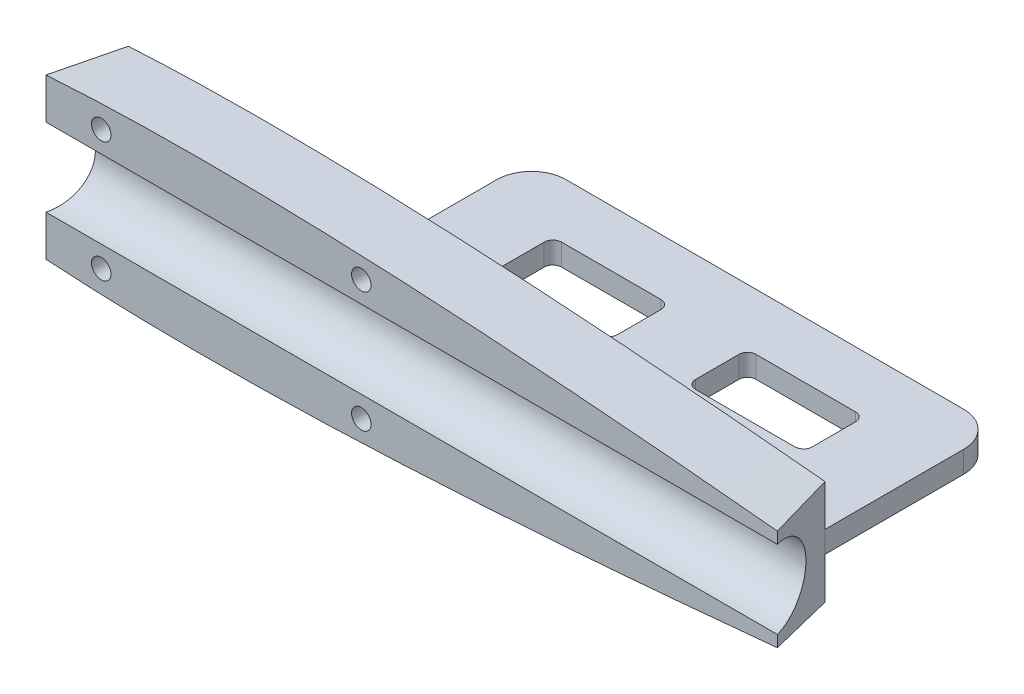
from build123d import *

# Parameters (mm, degrees)
BOSS_EXTRUDE1_DEPTH      = 40
CUT_EXTRUDE6_DEPTH       = 329.032621942
CUT_EXTRUDE6_DEPTH_BACK  = 329.032621942
SKETCH6_R                = 9
SKETCH10_W               = 325
SKETCH10_H               = 500
CUT_EXTRUDE8_DEPTH       = 327.543107499
CUT_EXTRUDE9_DEPTH       = 326.930055462
CUT_EXTRUDE9_DEPTH_BACK  = 326.930055462
CUT_EXTRUDE10_DEPTH      = 326.930055462
CUT_EXTRUDE10_DEPTH_BACK = 326.930055462
BOSS_EXTRUDE2_DEPTH      = 2.5
BOSS_EXTRUDE2_DEPTH_BACK = 2.5
SKETCH16_R               = 2.25
CUT_EXTRUDE14_DEPTH      = 235.265663364
SKETCH17_R               = 3.5
CUT_EXTRUDE16_DEPTH      = 3.5


with BuildPart() as part:
    # Sketch5 → Boss-Extrude1 (new body)
    with BuildSketch(Plane.XY):
        with BuildLine():
            Line((325, 0.409500093), (325, -0.409500093))
            add(Edge.make_bspline(
                [(325, 0.409500093), (324.20960678, 0.519399758), (322.004222006, 0.826045921), (318.131286116, 1.36247994), (313.205110102, 2.030429774), (307.754214135, 2.756561186), (301.981376014, 3.507966638), (296.038050703, 4.262859606), (290.014777157, 5.014772743), (283.95743396, 5.755826172), (277.884033962, 6.480709267), (271.79937184, 7.191158341), (265.70867326, 7.888595961), (259.617942627, 8.571587439), (253.527208067, 9.237576813), (247.432327629, 9.886751154), (241.332260133, 10.522503127), (235.230560492, 11.144750656), (229.130839249, 11.750855507), (223.034064986, 12.340949196), (216.939113888, 12.914294606), (210.845263015, 13.470838224), (204.75300295, 14.009574305), (198.663296519, 14.53085901), (192.576797706, 15.032744837), (186.493961903, 15.514677146), (180.415624113, 15.97680962), (174.342680029, 16.417084214), (168.275982363, 16.834029747), (162.215629608, 17.227874269), (156.161040663, 17.595337287), (150.112779893, 17.937209662), (144.073390404, 18.251351492), (138.04635031, 18.536066857), (132.03404416, 18.78922029), (126.035776651, 19.00736586), (120.050052915, 19.188740067), (114.07633166, 19.331543819), (108.117235085, 19.435103873), (102.17717161, 19.496310732), (96.260359176, 19.510972589), (90.370148739, 19.477507746), (84.509133, 19.390761839), (78.68077076, 19.247624303), (72.889576442, 19.044369416), (67.142086799, 18.775812706), (61.447355472, 18.439456222), (55.818878859, 18.027708666), (50.275490507, 17.539374953), (44.843627175, 16.96681204), (39.558578916, 16.308464466), (34.470527645, 15.562762436), (29.646611554, 14.737102001), (25.171418091, 13.847801873), (21.127793712, 12.91360791), (17.569724258, 11.964983661), (14.504881071, 11.023001778), (11.900269075, 10.111292569), (9.708286733, 9.232236883), (7.872827773, 8.392559239), (6.333151205, 7.594846147), (5.034947748, 6.825688418), (3.930515344, 6.073724518), (2.981161903, 5.3371894), (2.17337223, 4.604078075), (1.50639492, 3.867781994), (0.976010289, 3.131854817), (0.573308223, 2.405238092), (0.282112492, 1.696997566), (0.092781659, 1.008622484), (-0.003875422, 0.334729508), (-0.003875422, -0.334729508), (0.092781659, -1.008622484), (0.282112492, -1.696997566), (0.573308223, -2.405238092), (0.976010289, -3.131854817), (1.50639492, -3.867781994), (2.17337223, -4.604078075), (2.981161903, -5.3371894), (3.930515344, -6.073724518), (5.034947748, -6.825688417), (6.333151205, -7.594846147), (7.872827774, -8.392559236), (9.708286731, -9.232236898), (11.900269086, -10.1112925), (14.504881016, -11.023002106), (17.569724515, -11.964982123), (21.127792532, -12.913614983), (25.17142334, -13.847770423), (29.646571178, -14.737232518), (34.470598676, -15.562209675), (39.558539429, -16.308618639), (44.843633825, -16.966768477), (50.275488671, -17.539386981), (55.818879362, -18.02770537), (61.447355334, -18.439457121), (67.142086836, -18.775812462), (72.889576432, -19.044369482), (78.680770762, -19.247624285), (84.509132999, -19.390761843), (90.37014874, -19.477507745), (96.260359176, -19.51097259), (102.17717161, -19.496310732), (108.117235085, -19.435103873), (114.07633166, -19.331543819), (120.050052915, -19.188740067), (126.035776651, -19.00736586), (132.03404416, -18.78922029), (138.04635031, -18.536066857), (144.073390404, -18.251351492), (150.112779893, -17.937209662), (156.161040663, -17.595337287), (162.215629608, -17.227874269), (168.275982363, -16.834029747), (174.342680029, -16.417084214), (180.415624113, -15.97680962), (186.493961903, -15.514677146), (192.576797706, -15.032744837), (198.663296519, -14.53085901), (204.75300295, -14.009574305), (210.845263015, -13.470838224), (216.939113888, -12.914294606), (223.034064986, -12.340949196), (229.130839249, -11.750855507), (235.230560492, -11.144750656), (241.332260133, -10.522503127), (247.432327629, -9.886751154), (253.527208067, -9.237576813), (259.617942627, -8.571587439), (265.70867326, -7.888595961), (271.79937184, -7.191158341), (277.884033962, -6.480709267), (283.95743396, -5.755826172), (290.014777157, -5.014772742), (296.038050703, -4.262859606), (301.981376014, -3.507966638), (307.754214135, -2.756561186), (313.205110102, -2.030429774), (318.131286116, -1.36247994), (322.004222006, -0.826045921), (324.20960678, -0.519399758), (325, -0.409500093)],
                knots=[0, 0, 0, 0, 0.003612221, 0.010078953, 0.017698618, 0.026115111, 0.034970966, 0.04405038, 0.05323433, 0.06244757, 0.071673993, 0.080921319, 0.090177538, 0.099424342, 0.108664441, 0.117912199, 0.127169502, 0.136426595, 0.145675426, 0.154916495, 0.164153237, 0.173386649, 0.182615736, 0.191838089, 0.201053134, 0.210260393, 0.219458942, 0.228646747, 0.237822316, 0.246985224, 0.256137384, 0.265279416, 0.27440695, 0.283512193, 0.292591781, 0.301646285, 0.310681793, 0.319699068, 0.32869452, 0.33766016, 0.346588583, 0.355477412, 0.364322937, 0.373121614, 0.381867635, 0.390553005, 0.399166026, 0.407689628, 0.416098119, 0.424354887, 0.432412429, 0.440204728, 0.447630505, 0.454563638, 0.460855379, 0.466413319, 0.47122861, 0.475365774, 0.47890126, 0.481915077, 0.484498872, 0.486747127, 0.488741252, 0.490543179, 0.492182104, 0.493672831, 0.495031908, 0.49627906, 0.497424737, 0.498490166, 0.499502758, 0.500497254, 0.501509846, 0.502575275, 0.503720952, 0.504968104, 0.506327181, 0.507817908, 0.509456832, 0.51125876, 0.513252884, 0.51550114, 0.518084934, 0.521098752, 0.524634237, 0.528771401, 0.533586692, 0.539144632, 0.545436374, 0.552369506, 0.5597952, 0.567587571, 0.575645113, 0.583901881, 0.592310372, 0.600833974, 0.609446995, 0.618132365, 0.626878386, 0.635677063, 0.644522588, 0.653411417, 0.66233984, 0.67130548, 0.680300932, 0.689318207, 0.698353715, 0.707408219, 0.716487807, 0.72559305, 0.734720584, 0.743862616, 0.753014776, 0.762177684, 0.771353253, 0.780541058, 0.789739607, 0.798946866, 0.808161911, 0.817384264, 0.826613351, 0.835846763, 0.845083505, 0.854324574, 0.863573405, 0.872830498, 0.882087801, 0.891335559, 0.900575658, 0.909822462, 0.919078681, 0.928326007, 0.93755243, 0.94676567, 0.95594962, 0.965029034, 0.973884889, 0.982301382, 0.989921047, 0.996387779, 1, 1, 1, 1], degree=3))
        make_face()
    extrude(amount=BOSS_EXTRUDE1_DEPTH)

    # Sketch6 → Cut-Extrude6 (cut, two sides: drawn at the far end of the back side and taken through both)
    with BuildSketch(Plane(origin=(0, 0, 0), x_dir=(0, 0, -1), z_dir=(1, 0, 0)).offset(-CUT_EXTRUDE6_DEPTH_BACK)):
        with Locations((-15, 0)):
            Circle(SKETCH6_R)
    extrude(amount=CUT_EXTRUDE6_DEPTH + CUT_EXTRUDE6_DEPTH_BACK, mode=Mode.SUBTRACT)

    # Sketch10 → Cut-Extrude8 (cut, through all)
    with BuildSketch(Plane.XY.offset(15)):
        with Locations((162.5, 0)):
            Rectangle(SKETCH10_W, SKETCH10_H)
    extrude(amount=CUT_EXTRUDE8_DEPTH, mode=Mode.SUBTRACT)

    # Sketch11 → Cut-Extrude9 (cut, two sides: drawn at the far end of the back side and taken through both)
    with BuildSketch(Plane(origin=(0, 0, 0), x_dir=(1, 0, 0), z_dir=(0, 1, 0)).offset(-CUT_EXTRUDE9_DEPTH_BACK)):
        Polygon((65.25, 0), (61.25, -15), (0, -15), (0, 0), align=None)
    extrude(amount=CUT_EXTRUDE9_DEPTH + CUT_EXTRUDE9_DEPTH_BACK, mode=Mode.SUBTRACT)

    # Sketch12 → Cut-Extrude10 (cut, two sides: drawn at the far end of the back side and taken through both)
    with BuildSketch(Plane(origin=(0, 0, 0), x_dir=(1, 0, 0), z_dir=(0, 1, 0)).offset(-CUT_EXTRUDE10_DEPTH_BACK)):
        Polygon((230, -15), (226, 0), (325, 0), (325, -15), align=None)
    extrude(amount=CUT_EXTRUDE10_DEPTH + CUT_EXTRUDE10_DEPTH_BACK, mode=Mode.SUBTRACT)

    # Sketch13 → Boss-Extrude2 (add, two sides: drawn at the far end of the back side and taken through both)
    with BuildSketch(Plane(origin=(0, 0, 0), x_dir=(1, 0, 0), z_dir=(0, 1, 0)).offset(-BOSS_EXTRUDE2_DEPTH_BACK)):
        with BuildLine():
            Line((118.25, 0), (226, 0))
            Line((226, 0), (226, 32))
            ThreePointArc((226, 32), (223.656854249, 37.656854249), (218, 40))
            Line((218, 40), (126.25, 40))
            ThreePointArc((126.25, 40), (120.593145751, 37.656854249), (118.25, 32))
            Line((118.25, 32), (118.25, 0))
        make_face()
        with BuildLine():
            Line((138.208333333, 13), (161.145833333, 13))
            ThreePointArc((161.145833333, 13), (162.560046896, 13.585786438), (163.145833333, 15))
            Line((163.145833333, 15), (163.145833333, 25))
            ThreePointArc((163.145833333, 25), (162.560046896, 26.414213562), (161.145833333, 27))
            Line((161.145833333, 27), (138.208333333, 27))
            ThreePointArc((138.208333333, 27), (136.794119771, 26.414213562), (136.208333333, 25))
            Line((136.208333333, 25), (136.208333333, 15))
            ThreePointArc((136.208333333, 15), (136.794119771, 13.585786438), (138.208333333, 13))
        make_face(mode=Mode.SUBTRACT)
        with BuildLine():
            Line((183.104166667, 13), (206.041666667, 13))
            ThreePointArc((206.041666667, 13), (207.455880229, 13.585786438), (208.041666667, 15))
            Line((208.041666667, 15), (208.041666667, 25))
            ThreePointArc((208.041666667, 25), (207.455880229, 26.414213562), (206.041666667, 27))
            Line((206.041666667, 27), (183.104166667, 27))
            ThreePointArc((183.104166667, 27), (181.689953104, 26.414213562), (181.104166667, 25))
            Line((181.104166667, 25), (181.104166667, 15))
            ThreePointArc((181.104166667, 15), (181.689953104, 13.585786438), (183.104166667, 13))
        make_face(mode=Mode.SUBTRACT)
    extrude(amount=BOSS_EXTRUDE2_DEPTH + BOSS_EXTRUDE2_DEPTH_BACK)

    # Sketch16 → Cut-Extrude14 (cut, through all)
    with BuildSketch(Plane.XY):
        with Locations((74, -13.9)):
            Circle(SKETCH16_R)
        with Locations((74, 13.9)):
            Circle(SKETCH16_R)
        with Locations((134, 13.9)):
            Circle(SKETCH16_R)
        with Locations((134, -13.9)):
            Circle(SKETCH16_R)
    extrude(amount=CUT_EXTRUDE14_DEPTH, mode=Mode.SUBTRACT)

    # Sketch17 → Cut-Extrude16 (cut)
    with BuildSketch(Plane.XY):
        with Locations((74, 13.9)):
            Circle(SKETCH17_R)
        with Locations((74, -13.9)):
            Circle(SKETCH17_R)
        with Locations((134, -13.9)):
            Circle(SKETCH17_R)
        with Locations((134, 13.9)):
            Circle(SKETCH17_R)
    extrude(amount=CUT_EXTRUDE16_DEPTH, mode=Mode.SUBTRACT)


solid = part.part
